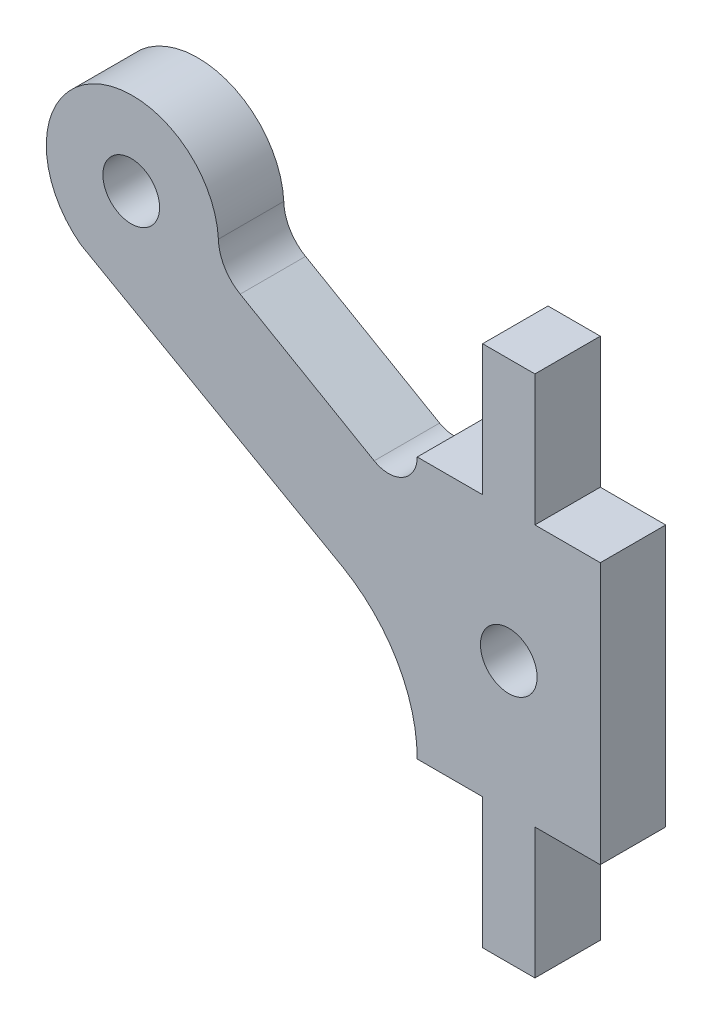
from build123d import *

# Parameters (mm, degrees)
MODEL_R             = 1.300004804
MODEL_R_2           = 1.3
BOSS_EXTRUDE1_DEPTH = 3


with BuildPart() as part:
    # Model → Boss-Extrude1 (new body)
    with BuildSketch(Plane.XY):
        with BuildLine():
            ThreePointArc((63.8572156, 46.472930832), (65.173213816, 46.473407151), (65.83136885, 47.613005099))
            Line((65.83136885, 47.613005099), (68.83138654, 47.613005099))
            Line((68.83138654, 47.613005099), (68.83138654, 53.61311115))
            Line((68.83138654, 53.61311115), (71.231386535, 53.61311115))
            Line((71.231386535, 53.61311115), (71.231386535, 47.61311115))
            Line((71.231386535, 47.61311115), (74.231368849, 47.61311115))
            Line((74.231368849, 47.61311115), (74.231368849, 35.61311115))
            Line((74.231368849, 35.61311115), (71.231386533, 35.61311115))
            Line((71.231386533, 35.61311115), (71.231386533, 29.61311115))
            Line((71.231386533, 29.61311115), (68.831386538, 29.61311115))
            Line((68.831386538, 29.61311115), (68.831386538, 35.61293443))
            Line((68.831386538, 35.61293443), (65.831368849, 35.61293443))
            ThreePointArc((65.831368849, 35.61293443), (64.915944961, 39.030436678), (62.414363078, 41.532318088))
            Line((62.414363078, 41.532318088), (50.393576956, 48.333374046))
            ThreePointArc((50.393576956, 48.333374046), (50.904413755, 54.977754044), (56.710901802, 51.707672034))
            ThreePointArc((56.710901802, 51.707672034), (56.990071165, 50.734303435), (57.710211056, 50.022418261))
            Line((57.710211056, 50.022418261), (63.8572156, 46.472930832))
        make_face()
        with Locations((52.711979414, 51.613979963)):
            Circle(MODEL_R, mode=Mode.SUBTRACT)
        with Locations((70.031775439, 41.612672771)):
            Circle(MODEL_R_2, mode=Mode.SUBTRACT)
    extrude(amount=BOSS_EXTRUDE1_DEPTH)


solid = part.part
